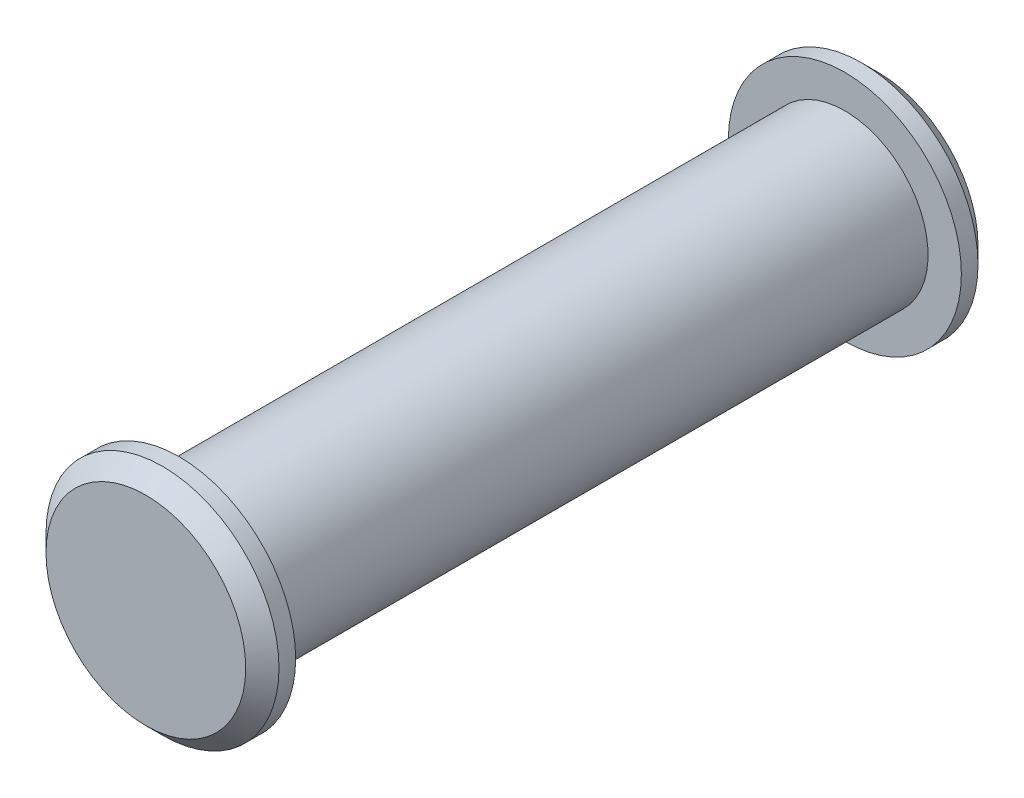
from build123d import *

# Parameters (mm, degrees)
SKETCH1_R           = 2.5
BOSS_EXTRUDE1_DEPTH = 10
SKETCH2_R           = 3.5
BOSS_EXTRUDE2_DEPTH = 1
CHAMFER1_SIZE       = 0.5


with BuildPart() as part:
    # Sketch1 → Boss-Extrude1 (new body, symmetric)
    with BuildSketch(Plane.XY):
        Circle(SKETCH1_R)
    extrude(amount=BOSS_EXTRUDE1_DEPTH, both=True)

    # Sketch2 → Boss-Extrude2 (add)
    with BuildSketch(Plane.XY.offset(10)):
        Circle(SKETCH2_R)
    boss_extrude2 = extrude(amount=BOSS_EXTRUDE2_DEPTH)

    # Mirror1: Boss-Extrude2 across plane
    add(boss_extrude2.mirror(Plane.XY))

    # Chamfer1
    chamfer1_edges = [part.edges().sort_by_distance(p)[0] for p in [
        (-3.5, 0, 11),
        (-3.5, 0, -11),
    ]]
    chamfer(chamfer1_edges, length=CHAMFER1_SIZE)


solid = part.part
